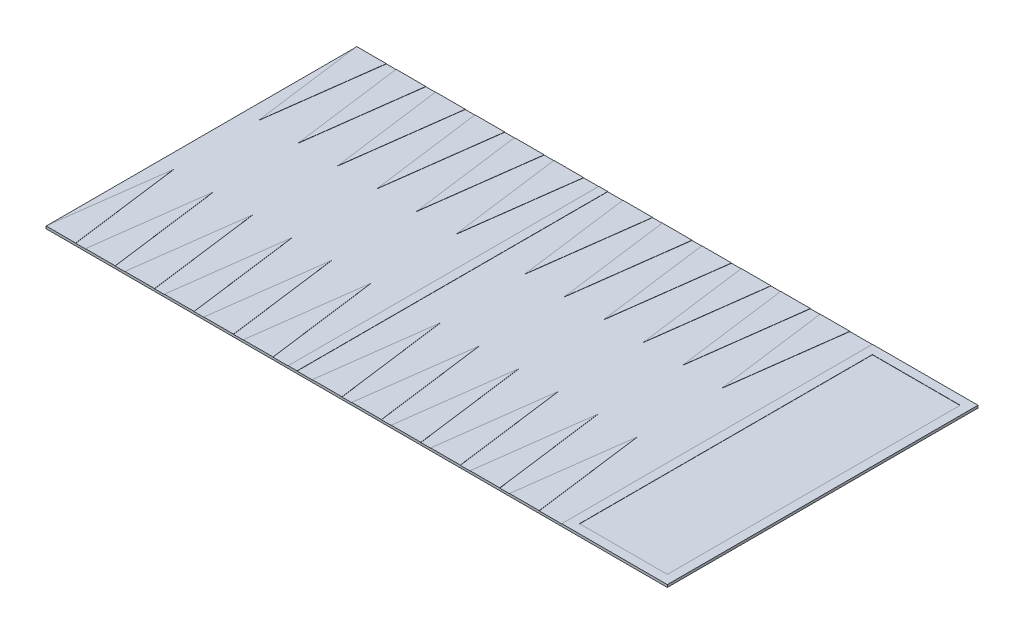
from build123d import *

# Parameters (mm, degrees)
SKETCH1_W           = 700
SKETCH1_H           = 350
BOSS_EXTRUDE1_DEPTH = 2.54
SKETCH2_W           = 10
SKETCH2_H           = 350
SKETCH2_H_2         = 330
BOSS_EXTRUDE2_DEPTH = 0.254
SCALE1_SCALE        = 1.5


with BuildPart() as part:
    # Sketch1 → Boss-Extrude1 (new body)
    with BuildSketch(Plane(origin=(0, 0, 0), x_dir=(1, 0, 0), z_dir=(0, 1, 0))):
        Rectangle(SKETCH1_W, SKETCH1_H)
    extrude(amount=BOSS_EXTRUDE1_DEPTH)

    # Sketch2 → Boss-Extrude2 (add)
    with BuildSketch(Plane(origin=(0, 2.54, 0), x_dir=(1, 0, 0), z_dir=(0, 1, 0))):
        Polygon((-316.560265613, 175), (-350, 175), (-333.280132806, 48), align=None)
        Polygon((-272.110265613, 175), (-305.55, 175), (-288.830132806, 48), align=None)
        Polygon((-227.660265613, 175), (-261.1, 175), (-244.380132806, 48), align=None)
        Polygon((-183.210265613, 175), (-216.65, 175), (-199.930132806, 48), align=None)
        Polygon((-138.760265613, 175), (-172.2, 175), (-155.480132806, 48), align=None)
        Polygon((-94.310265613, 175), (-127.75, 175), (-111.030132806, 48), align=None)
        with Locations((-72.168132806, 0)):
            Rectangle(SKETCH2_W, SKETCH2_H)
        Polygon((-16.586265613, 175), (-50.026, 175), (-33.306132806, 48), align=None)
        Polygon((27.863734387, 175), (-5.576, 175), (11.143867194, 48), align=None)
        Polygon((72.313734387, 175), (38.874, 175), (55.593867194, 48), align=None)
        Polygon((116.763734387, 175), (83.324, 175), (100.043867194, 48), align=None)
        Polygon((161.213734387, 175), (127.774, 175), (144.493867194, 48), align=None)
        Polygon((205.663734387, 175), (172.224, 175), (188.943867194, 48), align=None)
        Polygon((-350, -175), (-316.560265613, -175), (-333.280132806, -48), align=None)
        Polygon((-305.55, -175), (-272.110265613, -175), (-288.830132806, -48), align=None)
        Polygon((-261.1, -175), (-227.660265613, -175), (-244.380132806, -48), align=None)
        Polygon((-216.65, -175), (-183.210265613, -175), (-199.930132806, -48), align=None)
        Polygon((-172.2, -175), (-138.760265613, -175), (-155.480132806, -48), align=None)
        Polygon((-127.75, -175), (-94.310265613, -175), (-111.030132806, -48), align=None)
        Polygon((-33.306132806, -48), (-50.026, -175), (-16.586265613, -175), align=None)
        Polygon((11.143867194, -48), (-5.576, -175), (27.863734387, -175), align=None)
        Polygon((55.593867194, -48), (38.874, -175), (72.313734387, -175), align=None)
        Polygon((100.043867194, -48), (83.324, -175), (116.763734387, -175), align=None)
        Polygon((144.493867194, -48), (127.774, -175), (161.213734387, -175), align=None)
        Polygon((188.943867194, -48), (172.224, -175), (205.663734387, -175), align=None)
        Polygon((241.063734387, 175), (231.063734387, 175), (231.063734387, -175), (241.063734387, -175), (241.063734387, -165), (241.063734387, 165), align=None)
        Polygon((241.063734387, -165), (241.063734387, -175), (350, -175), (350, -165), (340, -165), align=None)
        with Locations((345, 0)):
            Rectangle(SKETCH2_W, SKETCH2_H_2)
        Polygon((350, 175), (241.063734387, 175), (241.063734387, 165), (340, 165), (350, 165), align=None)
    extrude(amount=BOSS_EXTRUDE2_DEPTH)


with BuildPart() as part_1:
    # Scale1: scaled about (-0.525903048, 1.305261187, 0)
    add(part.part.scale(SCALE1_SCALE).moved(Location((0.262951524, -0.652630593, 0))))


solid = part_1.part
